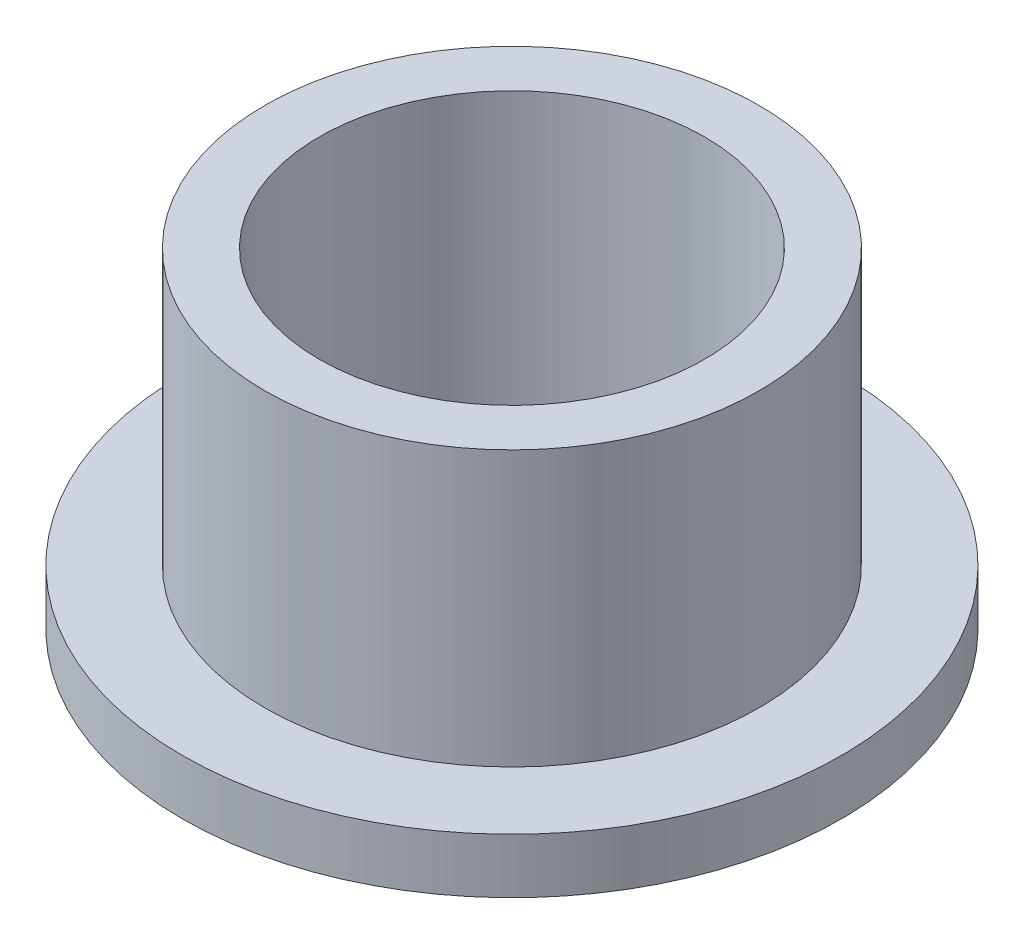
from build123d import *

# Parameters (mm, degrees)
SKETCH2_R           = 14.2875
SKETCH2_R_2         = 11.1379
BOSS_EXTRUDE1_DEPTH = 19.05
SKETCH3_R           = 19.05
SKETCH3_R_2         = 14.2875
BOSS_EXTRUDE2_DEPTH = 3.175


with BuildPart() as part:
    # Sketch2 → Boss-Extrude1 (new body)
    with BuildSketch(Plane(origin=(0, 0, 0), x_dir=(1, 0, 0), z_dir=(0, 1, 0))):
        Circle(SKETCH2_R)
        Circle(SKETCH2_R_2, mode=Mode.SUBTRACT)
    extrude(amount=BOSS_EXTRUDE1_DEPTH)

    # Sketch3 → Boss-Extrude2 (add)
    with BuildSketch(Plane(origin=(0, 0, 0), x_dir=(1, 0, 0), z_dir=(0, 1, 0))):
        Circle(SKETCH3_R)
        Circle(SKETCH3_R_2, mode=Mode.SUBTRACT)
    extrude(amount=BOSS_EXTRUDE2_DEPTH)


solid = part.part
